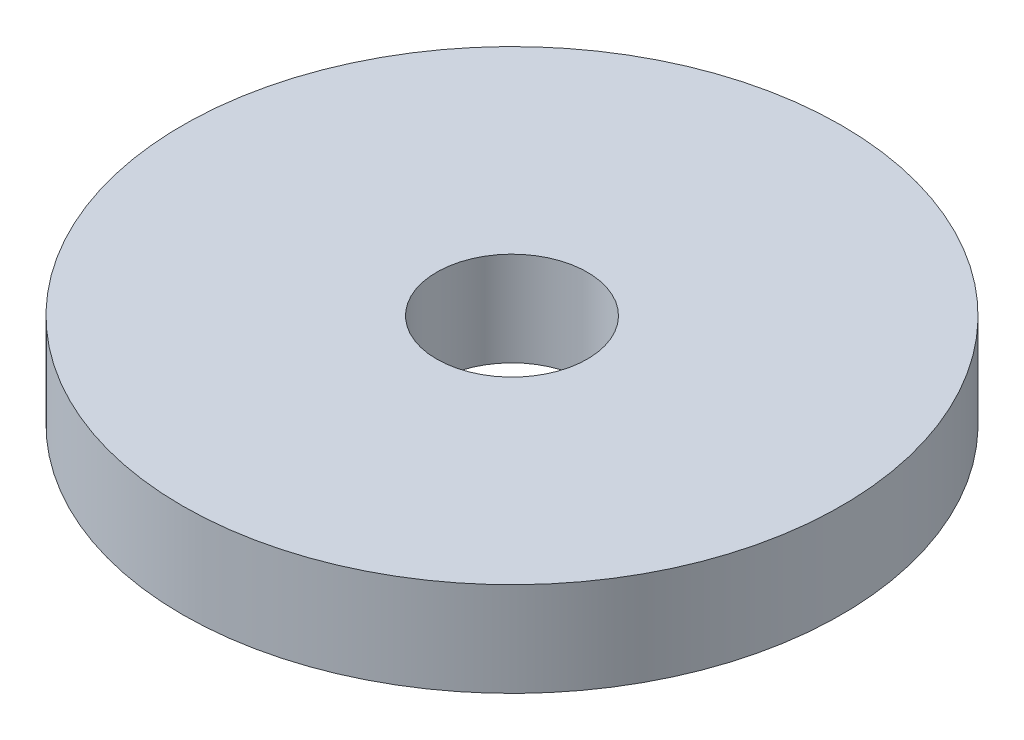
from build123d import *

# Parameters (mm, degrees)
SKETCH1_R           = 7
SKETCH1_R_2         = 1.6
BOSS_EXTRUDE1_DEPTH = 2


with BuildPart() as part:
    # Sketch1 → Boss-Extrude1 (new body)
    with BuildSketch(Plane(origin=(0, 0, 0), x_dir=(1, 0, 0), z_dir=(0, 1, 0))):
        Circle(SKETCH1_R)
        Circle(SKETCH1_R_2, mode=Mode.SUBTRACT)
    extrude(amount=BOSS_EXTRUDE1_DEPTH)


solid = part.part
